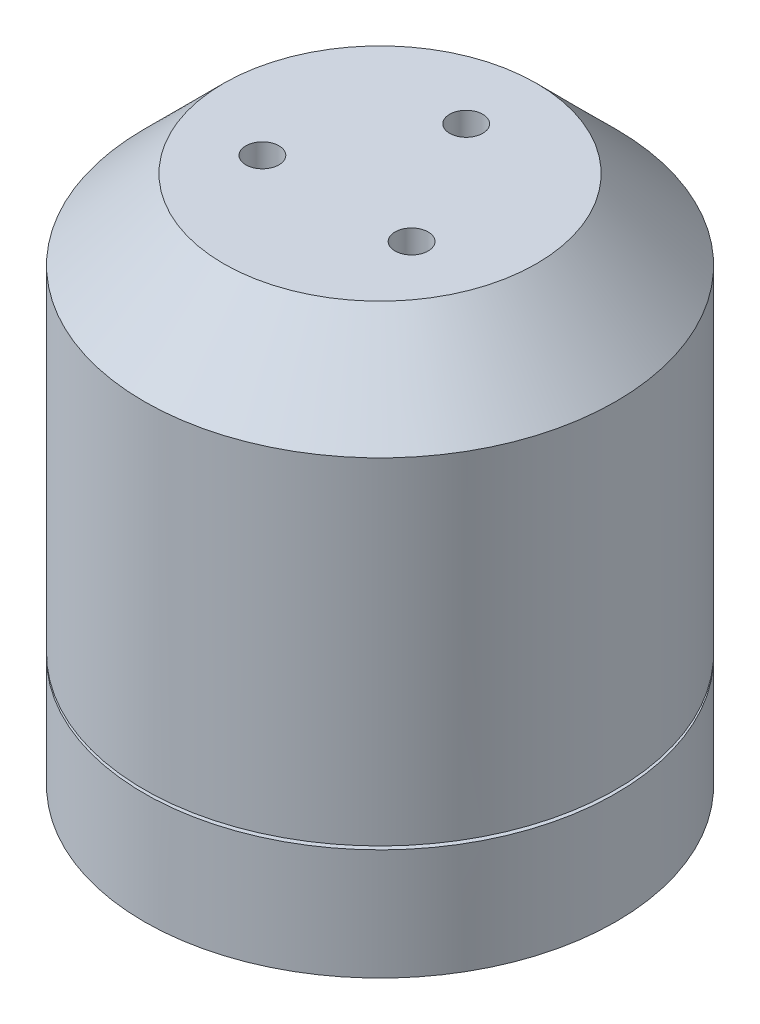
from build123d import *

# Parameters (mm, degrees)
SKETCH1_R           = 17.8
BOSS_EXTRUDE1_DEPTH = 20
SKETCH2_R           = 1.25
CUT_EXTRUDE1_DEPTH  = 12.7
CIRPATTERN1_COUNT   = 3
SKETCH3_R           = 1.5
CUT_EXTRUDE2_DEPTH  = 12.7
CIRPATTERN2_COUNT   = 4
CHAMFER1_SIZE       = 6
CUT_EXTRUDE3_START  = -8.382
SKETCH4_R           = 17.8
SKETCH4_R_2         = 2.5
CUT_EXTRUDE3_DEPTH  = 0.254


with BuildPart() as part:
    # Sketch1 → Boss-Extrude1 (new body, symmetric)
    with BuildSketch(Plane(origin=(0, 0, 0), x_dir=(1, 0, 0), z_dir=(0, 1, 0))):
        Circle(SKETCH1_R)
    extrude(amount=BOSS_EXTRUDE1_DEPTH, both=True)

    # Sketch2 → Cut-Extrude1 (cut)
    with BuildSketch(Plane(origin=(0, 20, 0), x_dir=(1, 0, 0), z_dir=(0, 1, 0))):
        with Locations((0, 6.5)):
            Circle(SKETCH2_R)
    cut_extrude1 = extrude(amount=-CUT_EXTRUDE1_DEPTH, mode=Mode.SUBTRACT)

    # CirPattern1: Cut-Extrude1 ×3 about axis
    cirpattern1_axis = Axis((0, 0, 0), (0, 1, 0))
    for i in range(1, CIRPATTERN1_COUNT):
        add(cut_extrude1.rotate(cirpattern1_axis, i * 360 / CIRPATTERN1_COUNT), mode=Mode.SUBTRACT)

    # Sketch3 → Cut-Extrude2 (cut)
    with BuildSketch(Plane.XZ.offset(20)):
        with Locations((0, 12.5)):
            Circle(SKETCH3_R)
    cut_extrude2 = extrude(amount=-CUT_EXTRUDE2_DEPTH, mode=Mode.SUBTRACT)

    # CirPattern2: Cut-Extrude2 ×4 about axis
    cirpattern2_axis = Axis((0, 0, 0), (0, 1, 0))
    for i in range(1, CIRPATTERN2_COUNT):
        add(cut_extrude2.rotate(cirpattern2_axis, i * 360 / CIRPATTERN2_COUNT), mode=Mode.SUBTRACT)

    # Chamfer1
    chamfer1_edges = [part.edges().sort_by_distance(p)[0] for p in [
        (-17.8, 20, 0),
    ]]
    chamfer(chamfer1_edges, length=CHAMFER1_SIZE)

    # Sketch4 → Cut-Extrude3 (cut)
    with BuildSketch(Plane.XZ.offset(20).offset(CUT_EXTRUDE3_START)):
        Circle(SKETCH4_R)
        Circle(SKETCH4_R_2, mode=Mode.SUBTRACT)
    extrude(amount=-CUT_EXTRUDE3_DEPTH, mode=Mode.SUBTRACT)


solid = part.part
